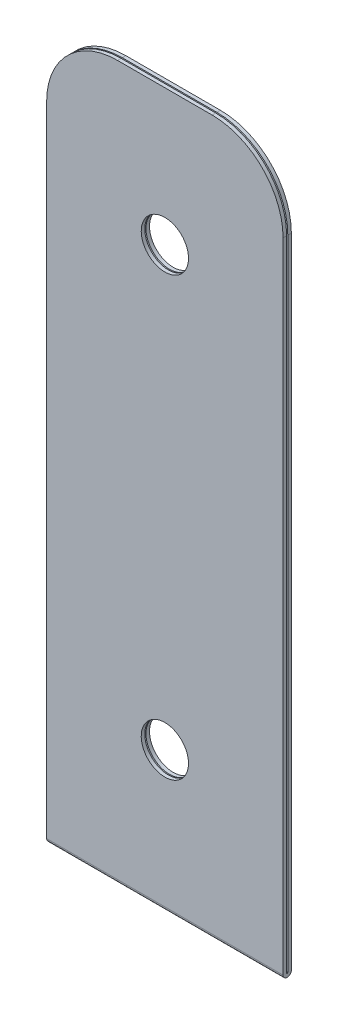
from build123d import *

# Parameters (mm, degrees)
BOSS_EXTRUDE1_DEPTH     = 10
FILLET1_R               = 3
SKETCH2_R               = 1
CUT_EXTRUDE1_DEPTH      = 1
CUT_EXTRUDE1_DEPTH_BACK = 1.35


with BuildPart() as part:
    # Sketch1 → Boss-Extrude1 (new body)
    with BuildSketch(Plane(origin=(0, 0, 0), x_dir=(0, 0, -1), z_dir=(1, 0, 0))):
        with BuildLine():
            Line((0, 30), (0, 0))
            ThreePointArc((0, 0), (-0.025, -0.025), (-0.05, 0))
            Line((-0.05, 0), (-0.05, 30))
            Line((-0.05, 30), (-0.2, 30))
            Line((-0.2, 30), (-0.2, 0))
            ThreePointArc((-0.2, 0), (-0.025, -0.175), (0.15, 0))
            Line((0.15, 0), (0.15, 30))
            Line((0.15, 30), (0, 30))
        make_face()
    extrude(amount=BOSS_EXTRUDE1_DEPTH)

    # Fillet1
    fillet1_edges = [part.edges().sort_by_distance(p)[0] for p in [
        (0, 30, -0.075),
        (10, 30, 0.125),
        (10, 30, -0.075),
        (0, 30, 0.125),
    ]]
    fillet(fillet1_edges, radius=FILLET1_R)

    # Sketch2 → Cut-Extrude1 (cut, two sides)
    with BuildSketch(Plane.XY.offset(0.2)) as cut_extrude1_sk:
        with Locations((5, 24.25)):
            Circle(SKETCH2_R)
        with Locations((5, 5.75)):
            Circle(SKETCH2_R)
    extrude(amount=CUT_EXTRUDE1_DEPTH, mode=Mode.SUBTRACT)
    extrude(cut_extrude1_sk.sketch, amount=-CUT_EXTRUDE1_DEPTH_BACK, mode=Mode.SUBTRACT)


solid = part.part
